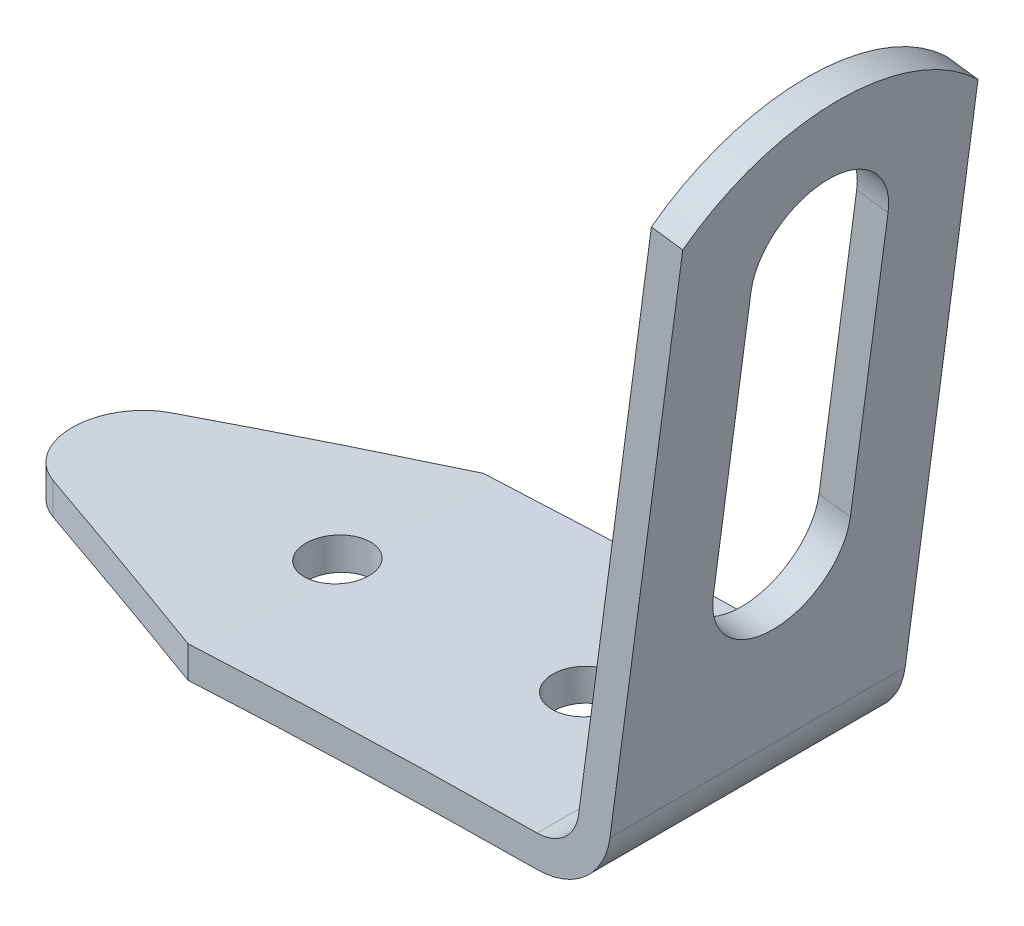
from build123d import *

# Parameters (mm, degrees)
EXTRUSION1_DEPTH             = 7
ENL_V_MAT_EXTRU_1_DEPTH      = 37.038682389
ENL_V_MAT_EXTRU_2_DEPTH      = 32.917281873
ENL_V_MAT_EXTRU_2_DEPTH_BACK = 2.378196501


with BuildPart() as part:
    # Esquisse1 → Extrusion1 (new body, symmetric)
    with BuildSketch(Plane.XY):
        with BuildLine():
            Line((0.403563953, 3.024571148), (4.232204488, 31.718897288))
            Line((4.232204488, 31.718897288), (2.745381178, 31.917281873))
            Line((2.745381178, 31.917281873), (-1.083259357, 3.222955733))
            ThreePointArc((-1.083259357, 3.222955733), (-1.742171349, 1.988036214), (-3.049340089, 1.487535348))
            ThreePointArc((-3.049340089, 1.487535348), (-17.587736804, 1.085119824), (-32.099393733, 0.116238776))
            Line((-32.099393733, 0.116238776), (-31.9703077, -1.378196501))
            ThreePointArc((-31.9703077, -1.378196501), (-17.51700864, -0.413211757), (-3.037077327, -0.012414526))
            ThreePointArc((-3.037077327, -0.012414526), (-0.749532032, 0.863461989), (0.403563953, 3.024571148))
        make_face()
    extrude(amount=EXTRUSION1_DEPTH, both=True)

    # Esquisse2 → Enlèv. mat.-Extru.1 (cut, through all)
    with BuildSketch(Plane(origin=(0, 0, 0), x_dir=(0, 0, -1), z_dir=(0.99121554, -0.13225639, 0))):
        with BuildLine():
            Line((-3.25, 11.75), (-3.25, 25.25))
            ThreePointArc((-3.25, 25.25), (0, 28.5), (3.25, 25.25))
            Line((3.25, 25.25), (3.25, 11.75))
            ThreePointArc((3.25, 11.75), (0, 8.5), (-3.25, 11.75))
        make_face()
        with BuildLine():
            Line((-7, 32), (-7, 29.141428429))
            ThreePointArc((-7, 29.141428429), (0, 32), (7, 29.141428429))
            Line((7, 29.141428429), (7, 32))
            ThreePointArc((7, 32), (0, 34.206555616), (-7, 32))
        make_face()
    extrude(amount=-ENL_V_MAT_EXTRU_1_DEPTH, mode=Mode.SUBTRACT)

    # Esquisse3 → Enlèv. mat.-Extru.2 (cut, two sides)
    with BuildSketch(Plane(origin=(0, 0, 0), x_dir=(1, 0, 0), z_dir=(0, 1, 0))) as enl_v_mat_extru_2_sk:
        with BuildLine():
            Line((-19.599393733, 7), (-30.206517298, 2.788239124))
            ThreePointArc((-30.206517298, 2.788239124), (-32.099393733, 0), (-30.206517298, -2.788239124))
            Line((-30.206517298, -2.788239124), (-19.599393733, -7))
            Line((-19.599393733, -7), (-32.099393733, -7))
            ThreePointArc((-32.099393733, -7), (-36.715166839, 0), (-32.099393733, 7))
            Line((-32.099393733, 7), (-19.599393733, 7))
        make_face()
    extrude(amount=ENL_V_MAT_EXTRU_2_DEPTH, mode=Mode.SUBTRACT)
    extrude(enl_v_mat_extru_2_sk.sketch, amount=-ENL_V_MAT_EXTRU_2_DEPTH_BACK, mode=Mode.SUBTRACT)

    # Esquisse4 → Enlèvement de matière-Révolution1 (revolve, cut)
    with BuildSketch(Plane.XY, mode=Mode.PRIVATE) as enl_vement_de_mati_re_r_volution1_sk:
        Polygon((-20.993708492, 29.083821309), (-19.397261786, -1.378196501), (-20.899320305, -1.378196501), (-22.495767011, 29.083821309), align=None)
    revolve(enl_vement_de_mati_re_r_volution1_sk.sketch.rotate(Axis((0, -371.5, 0), (-0.052335956, 0.998629535, 0)), 180), axis=Axis((0, -371.5, 0), (-0.052335956, 0.998629535, 0)), mode=Mode.SUBTRACT)  # turned: the seam where the file's is

    # Esquisse5 → Enlèvement de matière-Révolution2 (revolve, cut)
    with BuildSketch(Plane.XY, mode=Mode.PRIVATE) as enl_vement_de_mati_re_r_volution2_sk:
        Polygon((-9.530265596, 11.845167183), (-9.263238962, -0.902551216), (-7.763567936, -0.871137586), (-8.029936549, 11.845167183), align=None)
    revolve(enl_vement_de_mati_re_r_volution2_sk.sketch.rotate(Axis((0, -371.5, 0), (-0.02094242, 0.999780683, 0)), 180), axis=Axis((0, -371.5, 0), (-0.02094242, 0.999780683, 0)), mode=Mode.SUBTRACT)  # turned: the seam where the file's is


solid = part.part
